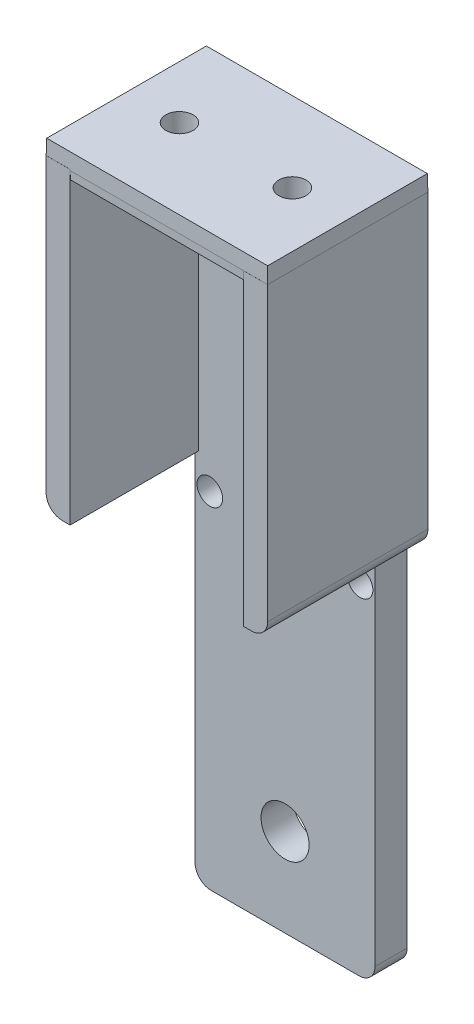
from build123d import *

# Parameters (mm, degrees)
ESQUISSE1_W                  = 22.45
ESQUISSE1_H                  = 85
BOSS_EXTRU_1_DEPTH           = 4
ESQUISSE2_R                  = 3
ENL_V_MAT_EXTRU_1_DEPTH      = 4
ESQUISSE3_R                  = 1.6
ENL_V_MAT_EXTRU_2_DEPTH      = 4
ESQUISSE4_W                  = 3
ESQUISSE4_H                  = 38.437504141
BOSS_EXTRU_2_DEPTH           = 20
CONG_1_R                     = 2
ESQUISSE7_W                  = 27.642878523
ESQUISSE7_H                  = 19.995510754
BOSS_EXTRU_3_DEPTH           = 2
BOSS_EXTRU_3_TAPER           = 1
BOSS_EXTRU_3_OTHER_WAY_DEPTH = 1
BOSS_EXTRU_3_OTHER_WAY_TAPER = 1
ESQUISSE8_R                  = 1.7
ENL_V_MAT_EXTRU_3_DEPTH      = 58


with BuildPart() as part:
    # Esquisse1 → Boss.-Extru.1 (new body)
    with BuildSketch(Plane.XY):
        Rectangle(ESQUISSE1_W, ESQUISSE1_H)
    extrude(amount=BOSS_EXTRU_1_DEPTH)

    # Esquisse2 → Enlèv. mat.-Extru.1 (cut)
    with BuildSketch(Plane.XY):
        with Locations((0, -31.5)):
            Circle(ESQUISSE2_R)
    extrude(amount=ENL_V_MAT_EXTRU_1_DEPTH, mode=Mode.SUBTRACT)

    # Esquisse3 → Enlèv. mat.-Extru.2 (cut)
    with BuildSketch(Plane.XY):
        with Locations((-9.391474789, 0.549780329)):
            Circle(ESQUISSE3_R)
        with Locations((9.359403649, 0.04974993)):
            Circle(ESQUISSE3_R)
    extrude(amount=ENL_V_MAT_EXTRU_2_DEPTH, mode=Mode.SUBTRACT)

    # Esquisse4 → Boss.-Extru.2 (add)
    with BuildSketch(Plane.XY):
        with Locations((12.325615706, 23.28124793)):
            Rectangle(ESQUISSE4_W, ESQUISSE4_H)
        with Locations((-12.317262817, 23.407822495)):
            Rectangle(ESQUISSE4_W, ESQUISSE4_H)
    extrude(amount=BOSS_EXTRU_2_DEPTH)

    # Congé1
    cong_1_edges = [part.edges().sort_by_distance(p)[0] for p in [
        (13.825615706, 4.062495859, 10),
        (-13.817262817, 4.189070425, 10),
        (-11.225, -42.5, 2),
        (11.225, -42.5, 2),
    ]]
    fillet(cong_1_edges, radius=CONG_1_R)

    # Esquisse7 → Boss.-Extru.3 (add)
    with BuildSketch(Plane(origin=(0, 42.5, 0), x_dir=(1, 0, 0), z_dir=(0, 1, 0))):
        with Locations((0.004176444, -9.997755377)):
            Rectangle(ESQUISSE7_W, ESQUISSE7_H)
    extrude(amount=BOSS_EXTRU_3_DEPTH, taper=BOSS_EXTRU_3_TAPER)

    # Esquisse7 → Boss.-Extru.3 other way (add)
    with BuildSketch(Plane(origin=(0, 42.5, 0), x_dir=(1, 0, 0), z_dir=(0, 1, 0))):
        with Locations((0.004176444, -9.997755377)):
            Rectangle(ESQUISSE7_W, ESQUISSE7_H)
    extrude(amount=-BOSS_EXTRU_3_OTHER_WAY_DEPTH, taper=BOSS_EXTRU_3_OTHER_WAY_TAPER)

    # Esquisse8 → Enlèv. mat.-Extru.3 (cut)
    with BuildSketch(Plane(origin=(0, 0, 0), x_dir=(1, 0, 0), z_dir=(0, 1, 0))):
        with Locations((6.913641528, -9.997755377)):
            Circle(ESQUISSE8_R)
        with Locations((-7.178390026, -9.997755377)):
            Circle(ESQUISSE8_R)
    extrude(amount=ENL_V_MAT_EXTRU_3_DEPTH, mode=Mode.SUBTRACT)


solid = part.part
